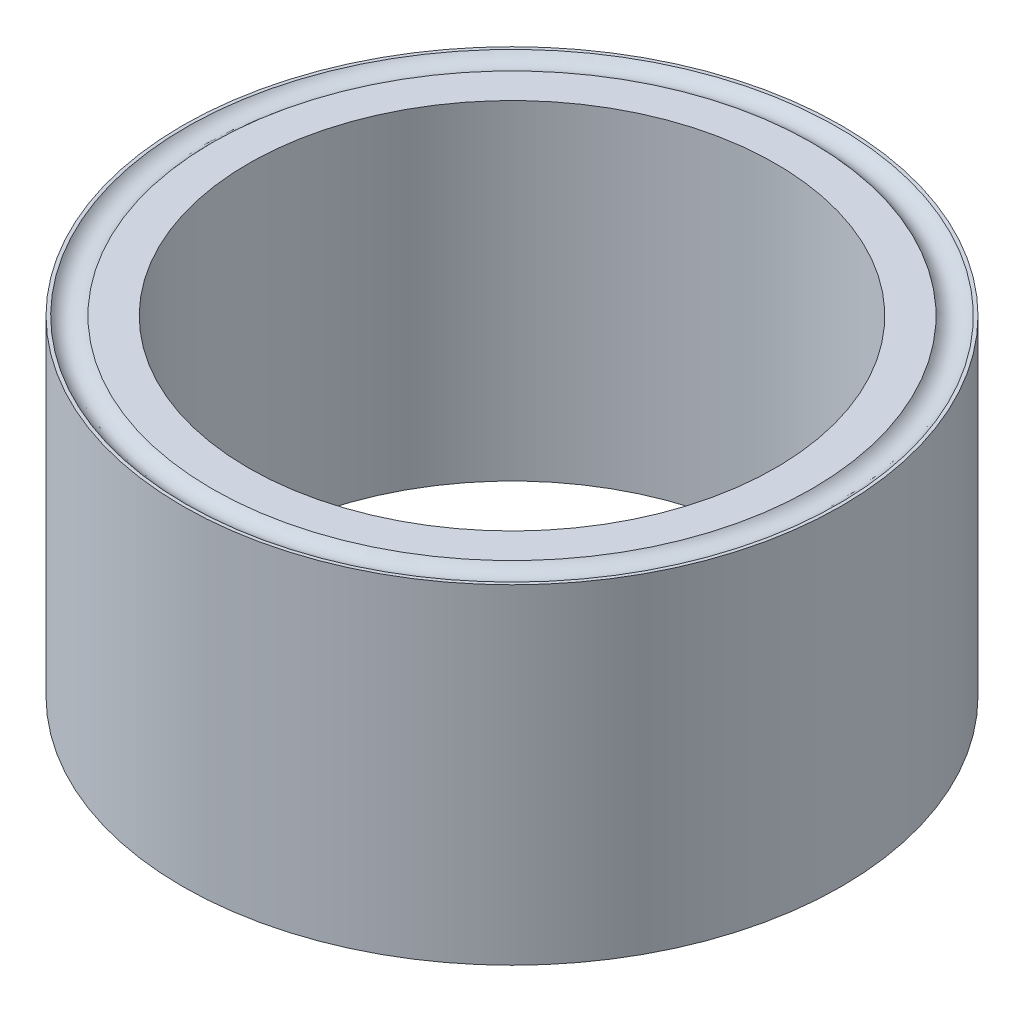
from build123d import *

# Parameters (mm, degrees)
SKETCH1_R           = 25
SKETCH1_R_2         = 20
BOSS_EXTRUDE1_DEPTH = 25


with BuildPart() as part:
    # Sketch1 → Boss-Extrude1 (new body)
    with BuildSketch(Plane(origin=(0, 0, 0), x_dir=(1, 0, 0), z_dir=(0, 1, 0))):
        Circle(SKETCH1_R)
        Circle(SKETCH1_R_2, mode=Mode.SUBTRACT)
    extrude(amount=BOSS_EXTRUDE1_DEPTH)

    # Sketch2 → Cut-Revolve1 (revolve, cut)
    with BuildSketch(Plane.XY):
        with BuildLine():
            Line((-24.75, 25), (-22.75, 25))
            ThreePointArc((-22.75, 25), (-23.75, 24.5), (-24.75, 25))
        make_face()
    revolve(axis=Axis((0, 26.219385416, 0), (0, -1, 0)), mode=Mode.SUBTRACT)


solid = part.part
